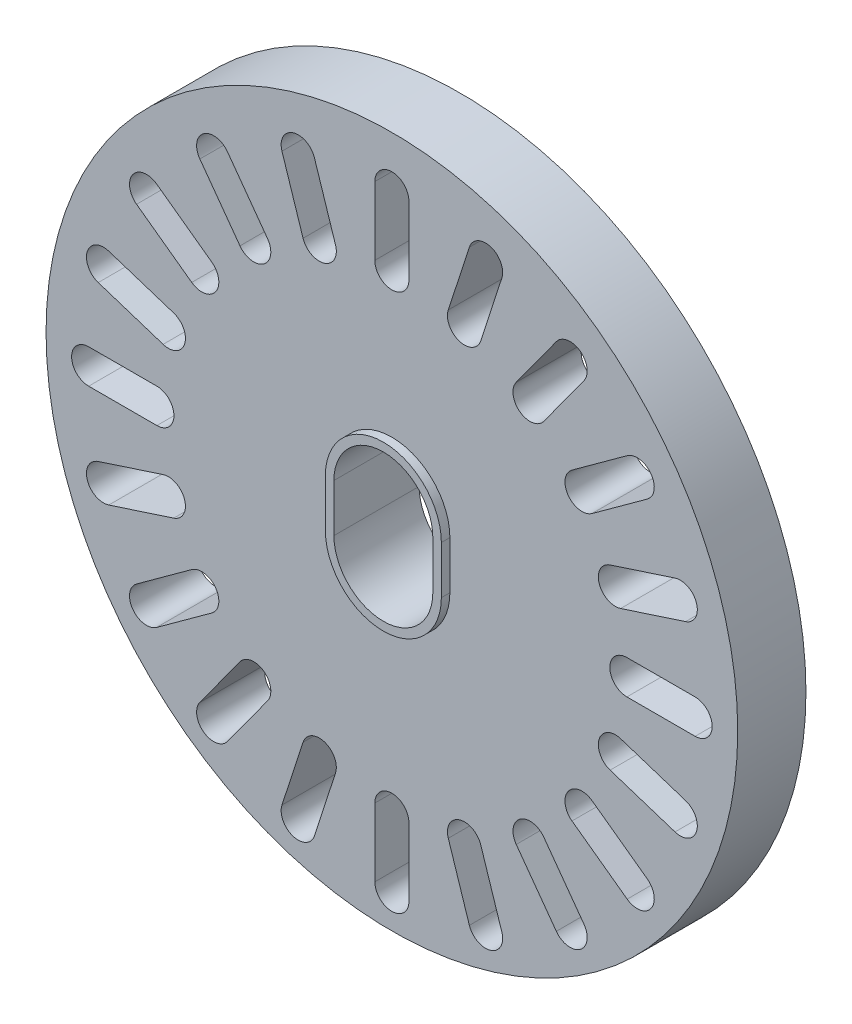
from build123d import *

# Parameters (mm, degrees)
SKETCH1_R           = 12.8778
BOSS_EXTRUDE1_DEPTH = 2.54
BOSS_EXTRUDE2_DEPTH = 0.3175


with BuildPart() as part:
    # Sketch1 → Boss-Extrude1 (new body)
    with BuildSketch(Plane.XY):
        Circle(SKETCH1_R)
        with BuildLine():
            Line((1.8415, 0.889), (1.8415, -0.889))
            ThreePointArc((1.8415, -0.889), (0, -2.7305), (-1.8415, -0.889))
            Line((-1.8415, -0.889), (-1.8415, 0.889))
            ThreePointArc((-1.8415, 0.889), (0, 2.7305), (1.8415, 0.889))
        make_face(mode=Mode.SUBTRACT)
        with BuildLine():
            Line((0.635, 10.9728), (0.635, 8.4328))
            ThreePointArc((0.635, 8.4328), (0, 7.7978), (-0.635, 8.4328))
            Line((-0.635, 8.4328), (-0.635, 10.9728))
            ThreePointArc((-0.635, 10.9728), (0, 11.6078), (0.635, 10.9728))
        make_face(mode=Mode.SUBTRACT)
        with BuildLine():
            Line((4.092815459, 10.223987594), (3.307912294, 7.808304043))
            ThreePointArc((3.307912294, 7.808304043), (2.507765614, 7.400608947), (2.100070518, 8.200755626))
            Line((2.100070518, 8.200755626), (2.884973684, 10.616439177))
            ThreePointArc((2.884973684, 10.616439177), (3.685120363, 11.024134274), (4.092815459, 10.223987594))
        make_face(mode=Mode.SUBTRACT)
        with BuildLine():
            Line((7.149997625, 8.443300936), (5.657023085, 6.388397771))
            ThreePointArc((5.657023085, 6.388397771), (4.770053658, 6.247915614), (4.629571502, 7.134885041))
            Line((4.629571502, 7.134885041), (6.122546043, 9.189788207))
            ThreePointArc((6.122546043, 9.189788207), (7.009515469, 9.330270363), (7.149997625, 8.443300936))
        make_face(mode=Mode.SUBTRACT)
        with BuildLine():
            Line((9.507288207, 5.805046043), (7.452385041, 4.312071502))
            ThreePointArc((7.452385041, 4.312071502), (6.565415614, 4.452553658), (6.705897771, 5.339523085))
            Line((6.705897771, 5.339523085), (8.760800936, 6.832497625))
            ThreePointArc((8.760800936, 6.832497625), (9.647770363, 6.692015469), (9.507288207, 5.805046043))
        make_face(mode=Mode.SUBTRACT)
        with BuildLine():
            Line((10.933939177, 2.567473684), (8.518255626, 1.782570518))
            ThreePointArc((8.518255626, 1.782570518), (7.718108947, 2.190265614), (8.125804043, 2.990412294))
            Line((8.125804043, 2.990412294), (10.541487594, 3.775315459))
            ThreePointArc((10.541487594, 3.775315459), (11.341634274, 3.367620363), (10.933939177, 2.567473684))
        make_face(mode=Mode.SUBTRACT)
        with BuildLine():
            Line((11.2903, -0.9525), (8.7503, -0.9525))
            ThreePointArc((8.7503, -0.9525), (8.1153, -0.3175), (8.7503, 0.3175))
            Line((8.7503, 0.3175), (11.2903, 0.3175))
            ThreePointArc((11.2903, 0.3175), (11.9253, -0.3175), (11.2903, -0.9525))
        make_face(mode=Mode.SUBTRACT)
        with BuildLine():
            Line((10.541487594, -4.410315459), (8.125804043, -3.625412294))
            ThreePointArc((8.125804043, -3.625412294), (7.718108947, -2.825265614), (8.518255626, -2.417570518))
            Line((8.518255626, -2.417570518), (10.933939177, -3.202473684))
            ThreePointArc((10.933939177, -3.202473684), (11.341634274, -4.002620363), (10.541487594, -4.410315459))
        make_face(mode=Mode.SUBTRACT)
        with BuildLine():
            Line((8.760800936, -7.467497625), (6.705897771, -5.974523085))
            ThreePointArc((6.705897771, -5.974523085), (6.565415614, -5.087553658), (7.452385041, -4.947071502))
            Line((7.452385041, -4.947071502), (9.507288207, -6.440046043))
            ThreePointArc((9.507288207, -6.440046043), (9.647770363, -7.327015469), (8.760800936, -7.467497625))
        make_face(mode=Mode.SUBTRACT)
        with BuildLine():
            Line((6.122546043, -9.824788207), (4.629571502, -7.769885041))
            ThreePointArc((4.629571502, -7.769885041), (4.770053658, -6.882915614), (5.657023085, -7.023397771))
            Line((5.657023085, -7.023397771), (7.149997625, -9.078300936))
            ThreePointArc((7.149997625, -9.078300936), (7.009515469, -9.965270363), (6.122546043, -9.824788207))
        make_face(mode=Mode.SUBTRACT)
        with BuildLine():
            Line((2.884973684, -11.251439177), (2.100070518, -8.835755626))
            ThreePointArc((2.100070518, -8.835755626), (2.507765614, -8.035608947), (3.307912294, -8.443304043))
            Line((3.307912294, -8.443304043), (4.092815459, -10.858987594))
            ThreePointArc((4.092815459, -10.858987594), (3.685120363, -11.659134274), (2.884973684, -11.251439177))
        make_face(mode=Mode.SUBTRACT)
        with BuildLine():
            Line((-0.635, -11.6078), (-0.635, -9.0678))
            ThreePointArc((-0.635, -9.0678), (0, -8.4328), (0.635, -9.0678))
            Line((0.635, -9.0678), (0.635, -11.6078))
            ThreePointArc((0.635, -11.6078), (0, -12.2428), (-0.635, -11.6078))
        make_face(mode=Mode.SUBTRACT)
        with BuildLine():
            Line((-4.092815459, -10.858987594), (-3.307912294, -8.443304043))
            ThreePointArc((-3.307912294, -8.443304043), (-2.507765614, -8.035608947), (-2.100070518, -8.835755626))
            Line((-2.100070518, -8.835755626), (-2.884973684, -11.251439177))
            ThreePointArc((-2.884973684, -11.251439177), (-3.685120363, -11.659134274), (-4.092815459, -10.858987594))
        make_face(mode=Mode.SUBTRACT)
        with BuildLine():
            Line((-7.149997625, -9.078300936), (-5.657023085, -7.023397771))
            ThreePointArc((-5.657023085, -7.023397771), (-4.770053658, -6.882915614), (-4.629571502, -7.769885041))
            Line((-4.629571502, -7.769885041), (-6.122546043, -9.824788207))
            ThreePointArc((-6.122546043, -9.824788207), (-7.009515469, -9.965270363), (-7.149997625, -9.078300936))
        make_face(mode=Mode.SUBTRACT)
        with BuildLine():
            Line((-9.507288207, -6.440046043), (-7.452385041, -4.947071502))
            ThreePointArc((-7.452385041, -4.947071502), (-6.565415614, -5.087553658), (-6.705897771, -5.974523085))
            Line((-6.705897771, -5.974523085), (-8.760800936, -7.467497625))
            ThreePointArc((-8.760800936, -7.467497625), (-9.647770363, -7.327015469), (-9.507288207, -6.440046043))
        make_face(mode=Mode.SUBTRACT)
        with BuildLine():
            Line((-10.933939177, -3.202473684), (-8.518255626, -2.417570518))
            ThreePointArc((-8.518255626, -2.417570518), (-7.718108947, -2.825265614), (-8.125804043, -3.625412294))
            Line((-8.125804043, -3.625412294), (-10.541487594, -4.410315459))
            ThreePointArc((-10.541487594, -4.410315459), (-11.341634274, -4.002620363), (-10.933939177, -3.202473684))
        make_face(mode=Mode.SUBTRACT)
        with BuildLine():
            Line((-11.2903, 0.3175), (-8.7503, 0.3175))
            ThreePointArc((-8.7503, 0.3175), (-8.1153, -0.3175), (-8.7503, -0.9525))
            Line((-8.7503, -0.9525), (-11.2903, -0.9525))
            ThreePointArc((-11.2903, -0.9525), (-11.9253, -0.3175), (-11.2903, 0.3175))
        make_face(mode=Mode.SUBTRACT)
        with BuildLine():
            Line((-10.541487594, 3.775315459), (-8.125804043, 2.990412294))
            ThreePointArc((-8.125804043, 2.990412294), (-7.718108947, 2.190265614), (-8.518255626, 1.782570518))
            Line((-8.518255626, 1.782570518), (-10.933939177, 2.567473684))
            ThreePointArc((-10.933939177, 2.567473684), (-11.341634274, 3.367620363), (-10.541487594, 3.775315459))
        make_face(mode=Mode.SUBTRACT)
        with BuildLine():
            Line((-8.760800936, 6.832497625), (-6.705897771, 5.339523085))
            ThreePointArc((-6.705897771, 5.339523085), (-6.565415614, 4.452553658), (-7.452385041, 4.312071502))
            Line((-7.452385041, 4.312071502), (-9.507288207, 5.805046043))
            ThreePointArc((-9.507288207, 5.805046043), (-9.647770363, 6.692015469), (-8.760800936, 6.832497625))
        make_face(mode=Mode.SUBTRACT)
        with BuildLine():
            Line((-6.122546043, 9.189788207), (-4.629571502, 7.134885041))
            ThreePointArc((-4.629571502, 7.134885041), (-4.770053658, 6.247915614), (-5.657023085, 6.388397771))
            Line((-5.657023085, 6.388397771), (-7.149997625, 8.443300936))
            ThreePointArc((-7.149997625, 8.443300936), (-7.009515469, 9.330270363), (-6.122546043, 9.189788207))
        make_face(mode=Mode.SUBTRACT)
        with BuildLine():
            Line((-2.884973684, 10.616439177), (-2.100070518, 8.200755626))
            ThreePointArc((-2.100070518, 8.200755626), (-2.507765614, 7.400608947), (-3.307912294, 7.808304043))
            Line((-3.307912294, 7.808304043), (-4.092815459, 10.223987594))
            ThreePointArc((-4.092815459, 10.223987594), (-3.685120363, 11.024134274), (-2.884973684, 10.616439177))
        make_face(mode=Mode.SUBTRACT)
    extrude(amount=BOSS_EXTRUDE1_DEPTH)

    # Sketch2 → Boss-Extrude2 (add)
    with BuildSketch(Plane.XY.offset(2.54)):
        with BuildLine():
            Line((-2.159, 0.889), (-2.159, -0.889))
            ThreePointArc((-2.159, -0.889), (0, -3.048), (2.159, -0.889))
            Line((2.159, -0.889), (2.159, 0.889))
            ThreePointArc((2.159, 0.889), (0, 3.048), (-2.159, 0.889))
        make_face()
        with BuildLine():
            Line((1.8415, -0.889), (1.8415, 0.889))
            ThreePointArc((1.8415, 0.889), (0, 2.7305), (-1.8415, 0.889))
            Line((-1.8415, 0.889), (-1.8415, -0.889))
            ThreePointArc((-1.8415, -0.889), (0, -2.7305), (1.8415, -0.889))
        make_face(mode=Mode.SUBTRACT)
    boss_extrude2 = extrude(amount=BOSS_EXTRUDE2_DEPTH)

    # Mirror1: Boss-Extrude2 across plane
    add(boss_extrude2.mirror(Plane.XY.offset(1.27)))


solid = part.part
